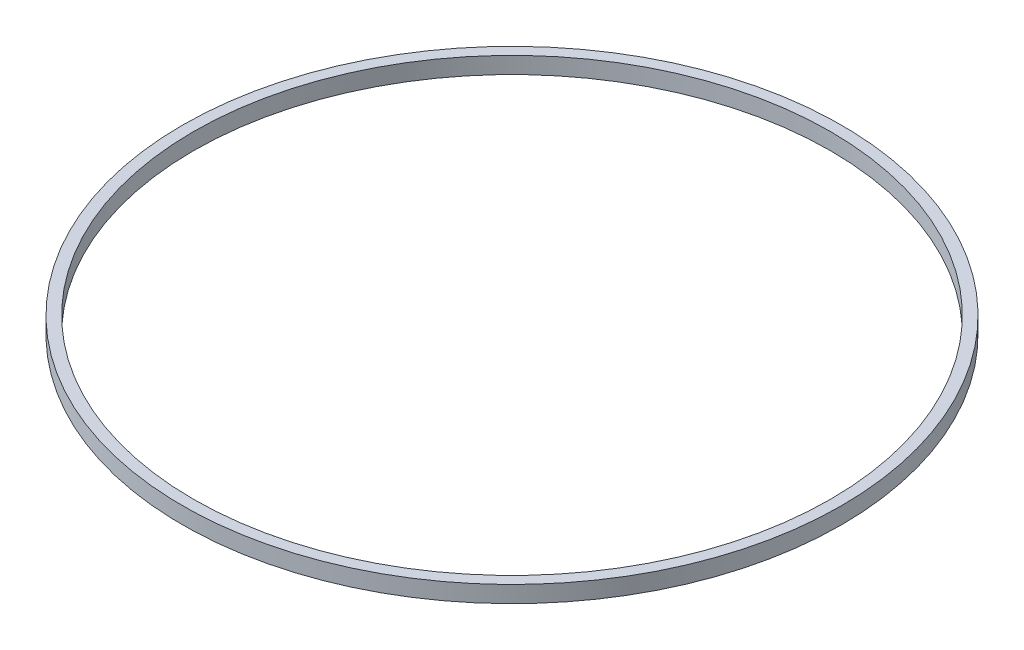
from build123d import *

# Parameters (mm, degrees)
ESQUISSE1_W = 2
ESQUISSE1_H = 3


with BuildPart() as part:
    # Esquisse1 → Révolution1 (revolve)
    with BuildSketch(Plane.XY):
        with Locations((-58.5, 1.5)):
            Rectangle(ESQUISSE1_W, ESQUISSE1_H)
    revolve(axis=Axis((0, 3, 0), (0, -1, 0)))


solid = part.part
